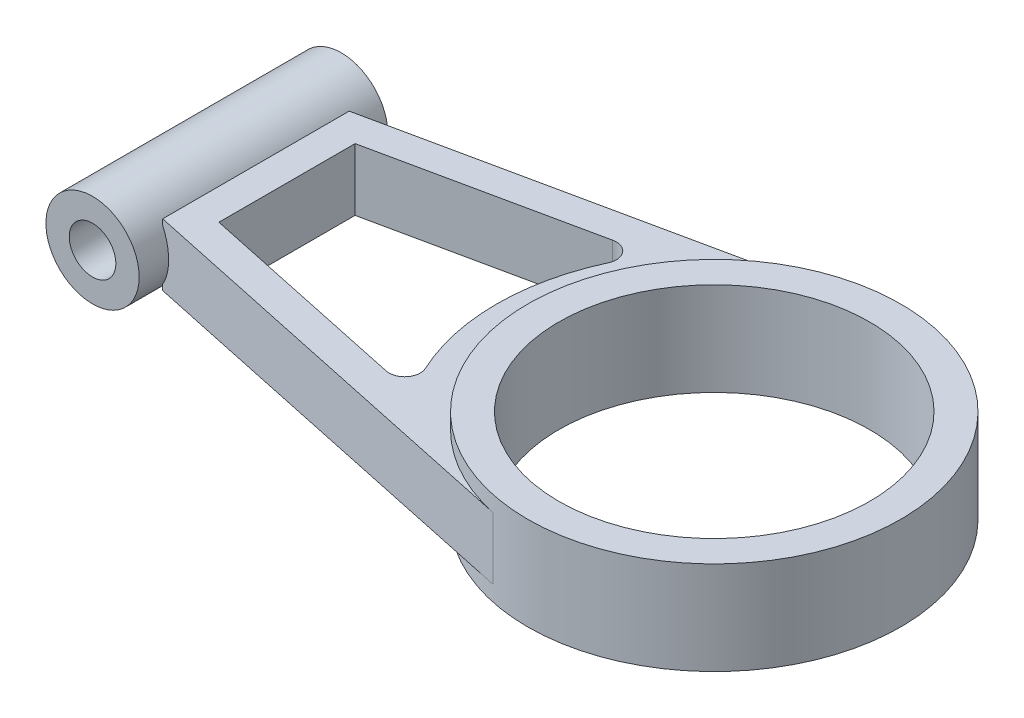
from build123d import *

# Parameters (mm, degrees)
CROQUIS2_R              = 50
SALIENTE_EXTRUIR3_DEPTH = 30
CORTAR_EXTRUIR1_DEPTH   = 5
CORTAR_EXTRUIR2_DEPTH   = 5
CROQUIS7_R              = 15
SALIENTE_EXTRUIR4_DEPTH = 40
CROQUIS7_2_R            = 15
SALIENTE_EXTRUIR5_DEPTH = 40
CROQUIS8_R              = 7.5
CORTAR_EXTRUIR3_DEPTH   = 101


with BuildPart() as part:
    # Croquis2 → Saliente-Extruir3 (new body)
    with BuildSketch(Plane(origin=(0, 0, 0), x_dir=(1, 0, 0), z_dir=(0, 1, 0))):
        with BuildLine():
            Line((-147.4451574, 30), (-12.474701449, 58.688856044))
            ThreePointArc((-12.474701449, 58.688856044), (60, 0), (-12.474701449, -58.688856044))
            Line((-12.474701449, -58.688856044), (-147.4451574, -30))
            Line((-147.4451574, -30), (-147.4451574, 30))
        make_face()
        Circle(CROQUIS2_R, mode=Mode.SUBTRACT)
        with BuildLine():
            Line((-137.4451574, -21.902159668), (-69.084440585, -36.432678588))
            ThreePointArc((-69.084440585, -36.432678588), (-64.13537775, -34.658954459), (-63.508556655, -29.439144545))
            ThreePointArc((-63.508556655, -29.439144545), (-70, 0), (-63.508556655, 29.439144545))
            ThreePointArc((-63.508556655, 29.439144545), (-64.13537775, 34.658954459), (-69.084440585, 36.432678588))
            Line((-69.084440585, 36.432678588), (-137.4451574, 21.902159668))
            Line((-137.4451574, 21.902159668), (-137.4451574, -21.902159668))
        make_face(mode=Mode.SUBTRACT)
    extrude(amount=SALIENTE_EXTRUIR3_DEPTH)

    # Croquis4 → Cortar-Extruir1 (cut)
    with BuildSketch(Plane(origin=(0, 0, 0), x_dir=(1, 0, 0), z_dir=(0, 1, 0))):
        with BuildLine():
            Line((-147.4451574, -30), (-12.474701449, -58.688856044))
            ThreePointArc((-12.474701449, -58.688856044), (-60, 0), (-12.474701449, 58.688856044))
            Line((-12.474701449, 58.688856044), (-147.4451574, 30))
            Line((-147.4451574, 30), (-147.4451574, -30))
        make_face()
        with BuildLine():
            Line((-69.084440585, 36.432678588), (-137.4451574, 21.902159668))
            Line((-137.4451574, 21.902159668), (-137.4451574, -21.902159668))
            Line((-137.4451574, -21.902159668), (-69.084440585, -36.432678588))
            ThreePointArc((-69.084440585, -36.432678588), (-64.13537775, -34.658954459), (-63.508556655, -29.439144545))
            ThreePointArc((-63.508556655, -29.439144545), (-70, 0), (-63.508556655, 29.439144545))
            ThreePointArc((-63.508556655, 29.439144545), (-64.13537775, 34.658954459), (-69.084440585, 36.432678588))
        make_face(mode=Mode.SUBTRACT)
    extrude(amount=CORTAR_EXTRUIR1_DEPTH, mode=Mode.SUBTRACT)

    # Croquis5 → Cortar-Extruir2 (cut)
    with BuildSketch(Plane(origin=(0, 30, 0), x_dir=(1, 0, 0), z_dir=(0, 1, 0))):
        with BuildLine():
            Line((-147.4451574, 30), (-147.4451574, -30))
            Line((-147.4451574, -30), (-12.474701449, -58.688856044))
            ThreePointArc((-12.474701449, -58.688856044), (-60, 0), (-12.474701449, 58.688856044))
            Line((-12.474701449, 58.688856044), (-147.4451574, 30))
        make_face()
        with BuildLine():
            Line((-137.4451574, -21.902159668), (-69.084440585, -36.432678588))
            ThreePointArc((-69.084440585, -36.432678588), (-64.13537775, -34.658954459), (-63.508556655, -29.439144545))
            ThreePointArc((-63.508556655, -29.439144545), (-70, 0), (-63.508556655, 29.439144545))
            ThreePointArc((-63.508556655, 29.439144545), (-64.13537775, 34.658954459), (-69.084440585, 36.432678588))
            Line((-69.084440585, 36.432678588), (-137.4451574, 21.902159668))
            Line((-137.4451574, 21.902159668), (-137.4451574, -21.902159668))
        make_face(mode=Mode.SUBTRACT)
    extrude(amount=-CORTAR_EXTRUIR2_DEPTH, mode=Mode.SUBTRACT)

    # Croquis7 → Saliente-Extruir4 (add)
    with BuildSketch(Plane.XY):
        with Locations((-160, 15)):
            Circle(CROQUIS7_R)
    extrude(amount=SALIENTE_EXTRUIR4_DEPTH)

    # Croquis7_2 → Saliente-Extruir5 (add)
    with BuildSketch(Plane.XY):
        with Locations((-160, 15)):
            Circle(CROQUIS7_2_R)
    extrude(amount=-SALIENTE_EXTRUIR5_DEPTH)

    # Croquis8 → Cortar-Extruir3 (cut, through all)
    with BuildSketch(Plane.XY.offset(40)):
        with Locations((-160, 15)):
            Circle(CROQUIS8_R)
    extrude(amount=-CORTAR_EXTRUIR3_DEPTH, mode=Mode.SUBTRACT)


solid = part.part
